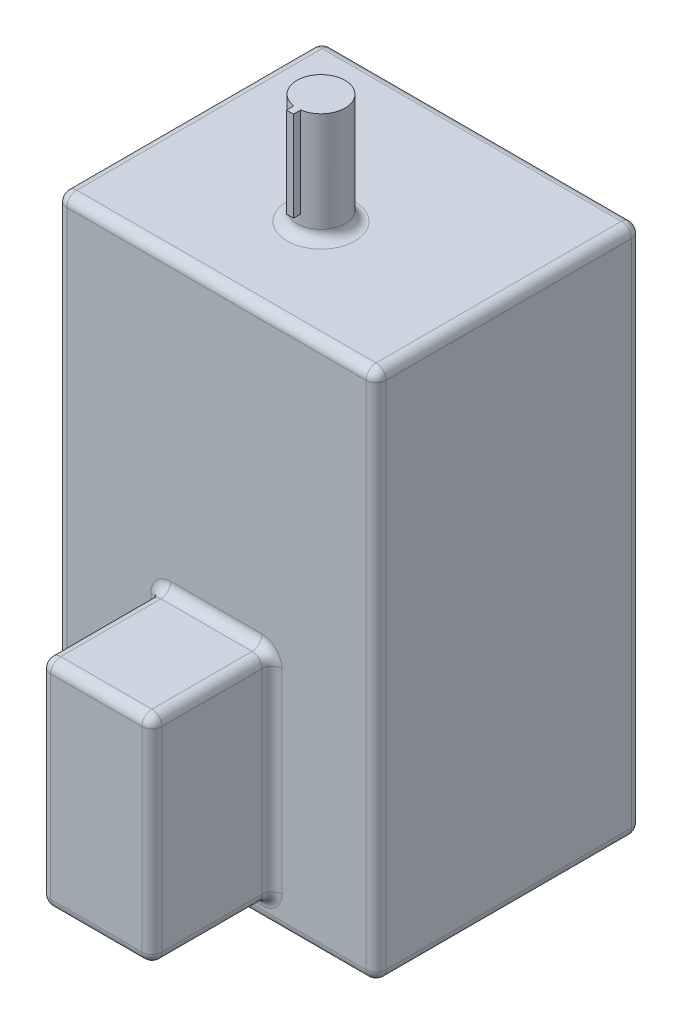
from build123d import *

# Parameters (mm, degrees)
SKETCH1_W           = 319
SKETCH1_H           = 530
BOSS_EXTRUDE1_DEPTH = 265
SKETCH2_W           = 111.097054908
SKETCH2_H           = 215.10280844
BOSS_EXTRUDE2_DEPTH = 120
SKETCH3_R           = 24
BOSS_EXTRUDE3_DEPTH = 110
SKETCH4_W           = 7
SKETCH4_H           = 14
BOSS_EXTRUDE4_DEPTH = 90
FILLET1_R           = 10


with BuildPart() as part:
    # Sketch1 → Boss-Extrude1 (new body)
    with BuildSketch(Plane.XY):
        Rectangle(SKETCH1_W, SKETCH1_H)
    extrude(amount=BOSS_EXTRUDE1_DEPTH)

    # Sketch2 → Boss-Extrude2 (add)
    with BuildSketch(Plane.XY.offset(265)):
        with Locations((0, -134.143784384)):
            Rectangle(SKETCH2_W, SKETCH2_H)
    extrude(amount=BOSS_EXTRUDE2_DEPTH)

    # Sketch3 → Boss-Extrude3 (add)
    with BuildSketch(Plane(origin=(0, 265, 0), x_dir=(1, 0, 0), z_dir=(0, 1, 0))):
        with Locations((-0.5, -160)):
            Circle(SKETCH3_R)
    extrude(amount=BOSS_EXTRUDE3_DEPTH)

    # Sketch4 → Boss-Extrude4 (add)
    with BuildSketch(Plane(origin=(0, 375, 0), x_dir=(1, 0, 0), z_dir=(0, 1, 0))):
        with Locations((-0.5, -184)):
            Rectangle(SKETCH4_W, SKETCH4_H)
    extrude(amount=-BOSS_EXTRUDE4_DEPTH)

    # Fillet1
    fillet1_edges = [part.edges().sort_by_distance(p)[0] for p in [
        (-159.5, 0, 265),
        (0, -265, 265),
        (55.548527454, -134.143784384, 265),
        (55.548527454, -241.695188604, 325),
        (0, -26.592380164, 265),
        (55.548527454, -26.592380164, 325),
        (-55.548527454, -134.143784384, 265),
        (-55.548527454, -26.592380164, 325),
        (0, -241.695188604, 265),
        (-55.548527454, -241.695188604, 325),
        (55.548527454, -134.143784384, 385),
        (0, -26.592380164, 385),
        (-55.548527454, -134.143784384, 385),
        (0, -241.695188604, 385),
        (-24.5, 265, 160),
        (159.5, 0, 265),
        (0, -265, 0),
        (-159.5, 0, 0),
        (0, 265, 0),
        (159.5, 0, 0),
        (0, 265, 265),
        (159.5, -265, 132.5),
        (-159.5, -265, 132.5),
        (-159.5, 265, 132.5),
        (159.5, 265, 132.5),
    ]]
    fillet(fillet1_edges, radius=FILLET1_R)


solid = part.part
